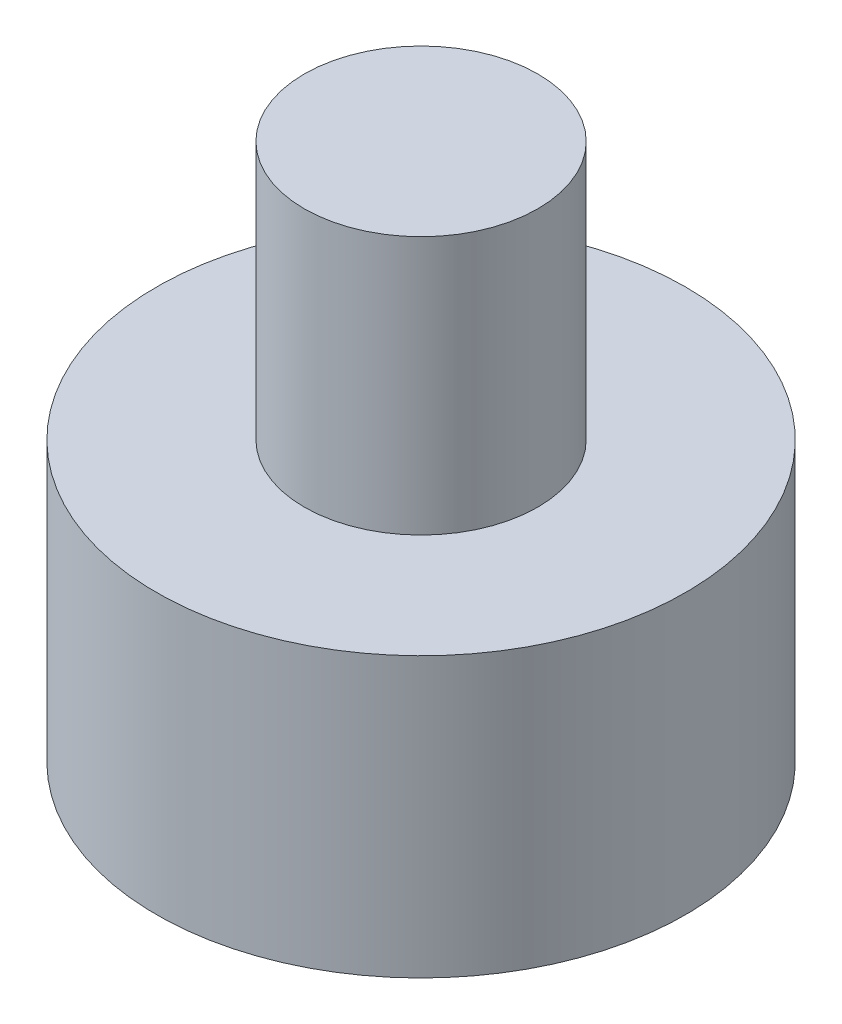
from build123d import *


with BuildPart() as part:
    # 스케치1 → 회전3 (revolve)
    with BuildSketch(Plane.XY):
        Polygon((0, 17.879556824), (0, 119.849227465), (22.158793812, 119.849227465), (22.158793812, 70.825347349), (50.200453238, 70.825347349), (50.200453238, 17.879556824), align=None)
    revolve(axis=Axis((0, 17.879556824, 0), (0, 1, 0)))


solid = part.part
